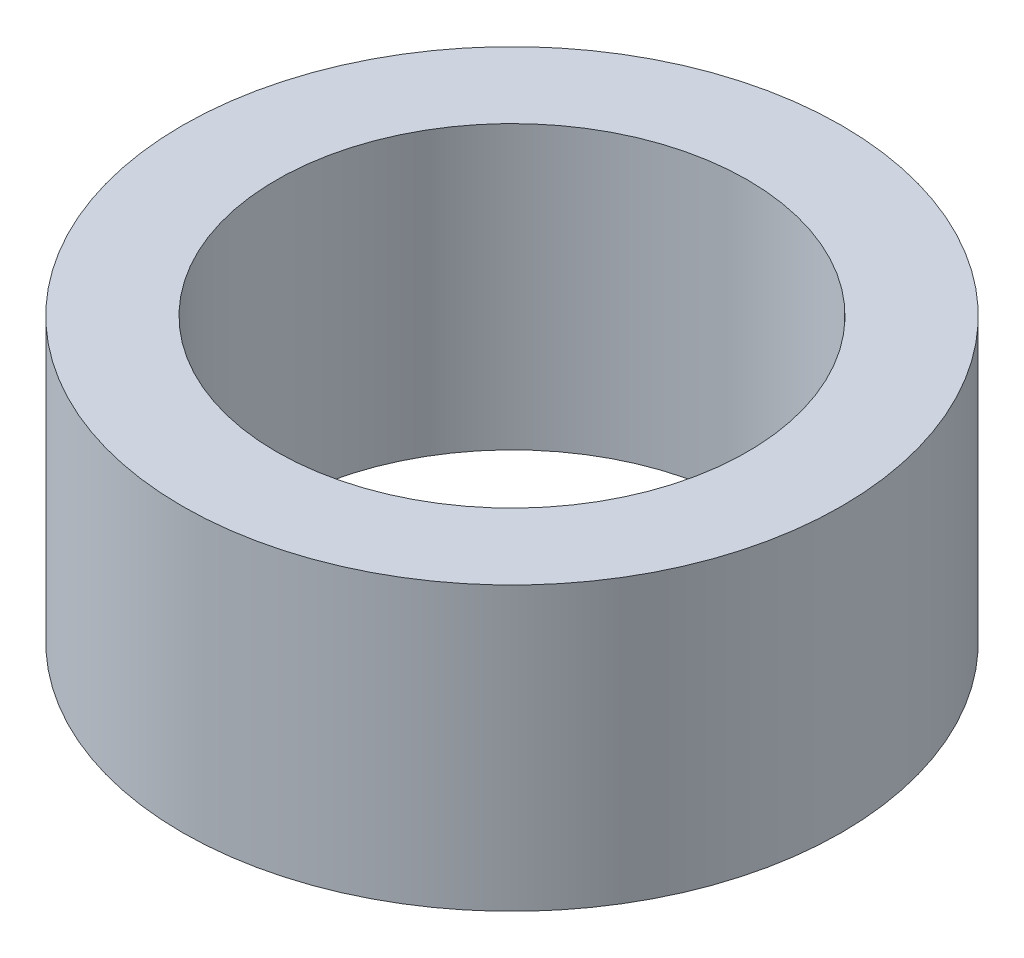
from build123d import *

# Parameters (mm, degrees)
CROQUIS1_R              = 17.5
CROQUIS1_R_2            = 12.5
SALIENTE_EXTRUIR1_DEPTH = 15


with BuildPart() as part:
    # Croquis1 → Saliente-Extruir1 (new body)
    with BuildSketch(Plane(origin=(0, 0, 0), x_dir=(1, 0, 0), z_dir=(0, 1, 0))):
        Circle(CROQUIS1_R)
        Circle(CROQUIS1_R_2, mode=Mode.SUBTRACT)
    extrude(amount=SALIENTE_EXTRUIR1_DEPTH)


solid = part.part
